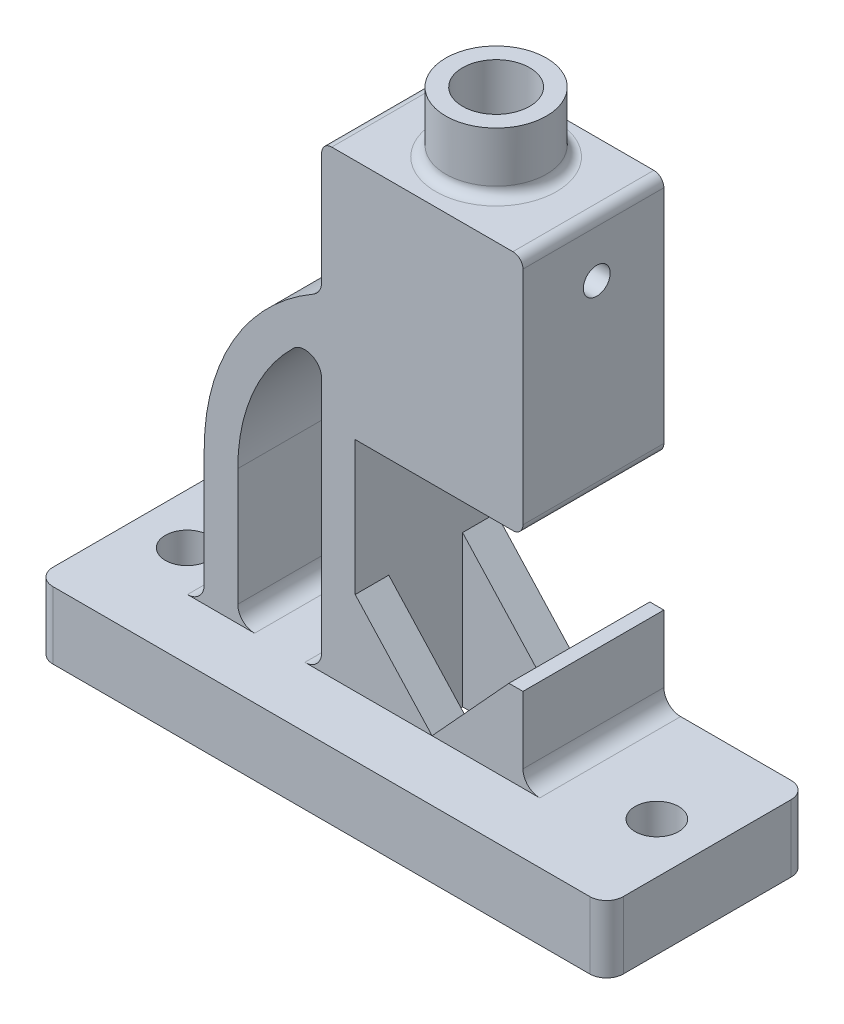
from build123d import *

# Parameters (mm, degrees)
BOSS_EXTRUDE1_DEPTH     = 20
BOSS_EXTRUDE4_START     = -30
BOSS_EXTRUDE4_DEPTH     = 42
SKETCH10_W              = 40
SKETCH10_H              = 22
CUT_EXTRUDE3_DEPTH      = 147
SKETCH11_R              = 15
BOSS_EXTRUDE5_DEPTH     = 18
CUT_EXTRUDE4_REACH      = 177
SKETCH12_R              = 10
FILLET1_R               = 3
SKETCH13_R              = 4
CUT_EXTRUDE5_DEPTH      = 86
CUT_EXTRUDE5_DEPTH_BACK = 86
CUT_EXTRUDE7_REACH      = 177
SKETCH16_R              = 6.5


with BuildPart() as part:
    # Sketch1 → Boss-Extrude1 (new body)
    with BuildSketch(Plane(origin=(0, 0, 0), x_dir=(1, 0, 0), z_dir=(0, 1, 0))):
        with BuildLine():
            Line((-80, 30), (80, 30))
            ThreePointArc((80, 30), (83.535533906, 28.535533906), (85, 25))
            Line((85, 25), (85, -25))
            ThreePointArc((85, -25), (83.535533906, -28.535533906), (80, -30))
            Line((80, -30), (-80, -30))
            ThreePointArc((-80, -30), (-83.535533906, -28.535533906), (-85, -25))
            Line((-85, -25), (-85, 25))
            ThreePointArc((-85, 25), (-83.535533906, 28.535533906), (-80, 30))
        make_face()
    extrude(amount=BOSS_EXTRUDE1_DEPTH)

    # Sketch2 → Boss-Extrude4 (add)
    with BuildSketch(Plane.XY.offset(BOSS_EXTRUDE4_START)):
        with BuildLine():
            Line((-17.90827935, 157), (42.09172065, 157))
            Line((42.09172065, 157), (42.09172065, 85))
            Line((42.09172065, 85), (-7.90827935, 85))
            Line((-7.90827935, 85), (-7.90827935, 45))
            Line((-7.90827935, 45), (15, 20))
            Line((15, 20), (37.90827935, 45))
            Line((37.90827935, 45), (42.09172065, 45))
            Line((42.09172065, 45), (42.09172065, 25))
            ThreePointArc((42.09172065, 25), (43.556186744, 21.464466094), (47.09172065, 20))
            Line((47.09172065, 20), (50, 20))
            Line((50, 20), (50, 17))
            Line((50, 17), (-58, 17))
            Line((-58, 17), (-58, 20))
            Line((-58, 20), (-57.90827935, 20))
            ThreePointArc((-57.90827935, 20), (-54.372745445, 21.464466094), (-52.90827935, 25))
            Line((-52.90827935, 25), (-52.90827935, 60))
            ThreePointArc((-52.90827935, 60), (-44.199930596, 92.5), (-20.40827935, 116.291651246))
            ThreePointArc((-20.40827935, 116.291651246), (-18.578152332, 118.121778265), (-17.90827935, 120.621778265))
            Line((-17.90827935, 120.621778265), (-17.90827935, 157))
        make_face()
        with BuildLine():
            Line((-17.90827935, 95.707142143), (-17.90827935, 25))
            ThreePointArc((-17.90827935, 25), (-19.372745445, 21.464466094), (-22.90827935, 20))
            Line((-22.90827935, 20), (-37.90827935, 20))
            ThreePointArc((-37.90827935, 20), (-41.443813256, 21.464466094), (-42.90827935, 25))
            Line((-42.90827935, 25), (-42.90827935, 60))
            ThreePointArc((-42.90827935, 60), (-38.615773866, 81.301408404), (-26.40827935, 99.277856357))
            ThreePointArc((-26.40827935, 99.277856357), (-20.971787677, 100.316914371), (-17.90827935, 95.707142143))
        make_face(mode=Mode.SUBTRACT)
    extrude(amount=BOSS_EXTRUDE4_DEPTH)

    # Sketch10 → Cut-Extrude3 (cut)
    with BuildSketch(Plane(origin=(0, 0, 0), x_dir=(1, 0, 0), z_dir=(0, 1, 0))):
        with Locations((12.09172065, 9)):
            Rectangle(SKETCH10_W, SKETCH10_H)
    extrude(amount=CUT_EXTRUDE3_DEPTH, mode=Mode.SUBTRACT)

    # Sketch11 → Boss-Extrude5 (add)
    with BuildSketch(Plane(origin=(0, 157, 0), x_dir=(1, 0, 0), z_dir=(0, 1, 0))):
        with Locations((12.09172065, 10)):
            Circle(SKETCH11_R)
    extrude(amount=BOSS_EXTRUDE5_DEPTH)

    # Sketch12 → Cut-Extrude4 (cut, up to next)
    with BuildSketch(Plane(origin=(0, 175, 0), x_dir=(1, 0, 0), z_dir=(0, 1, 0)), mode=Mode.PRIVATE) as cut_extrude4_sk1:
        with Locations((12.09172065, 10)):
            Circle(SKETCH12_R)
    cut_extrude4_tool1 = extrude(cut_extrude4_sk1.sketch, amount=-CUT_EXTRUDE4_REACH, mode=Mode.PRIVATE) & part.part
    add(cut_extrude4_tool1.solids().sort_by_distance((12.091721, 175, -10))[0], mode=Mode.SUBTRACT)

    # Fillet1
    fillet1_edges = [part.edges().sort_by_distance(p)[0] for p in [
        (-2.90827935, 157, -10),
        (42.09172065, 85, -9),
        (42.09172065, 157, -9),
        (-17.90827935, 157, -9),
    ]]
    fillet(fillet1_edges, radius=FILLET1_R)

    # Sketch13 → Cut-Extrude5 (cut, two sides)
    with BuildSketch(Plane(origin=(0, 0, 0), x_dir=(0, 0, -1), z_dir=(1, 0, 0))) as cut_extrude5_sk:
        with Locations((10, 140)):
            Circle(SKETCH13_R)
    extrude(amount=CUT_EXTRUDE5_DEPTH, mode=Mode.SUBTRACT)
    extrude(cut_extrude5_sk.sketch, amount=-CUT_EXTRUDE5_DEPTH_BACK, mode=Mode.SUBTRACT)

    # Sketch16 → Cut-Extrude7 (cut, up to next)
    with BuildSketch(Plane(origin=(0, 0, 0), x_dir=(1, 0, 0), z_dir=(0, 1, 0)), mode=Mode.PRIVATE) as cut_extrude7_sk1:
        with Locations((-70, 0)):
            Circle(SKETCH16_R)
    cut_extrude7_tool1 = extrude(cut_extrude7_sk1.sketch, amount=CUT_EXTRUDE7_REACH, mode=Mode.PRIVATE) & part.part
    add(cut_extrude7_tool1.solids().sort_by_distance((-70, 0, 0))[0], mode=Mode.SUBTRACT)
    # Sketch16 → Cut-Extrude7 (cut, up to next)
    with BuildSketch(Plane(origin=(0, 0, 0), x_dir=(1, 0, 0), z_dir=(0, 1, 0)), mode=Mode.PRIVATE) as cut_extrude7_sk2:
        with Locations((70, 0)):
            Circle(SKETCH16_R)
    cut_extrude7_tool2 = extrude(cut_extrude7_sk2.sketch, amount=CUT_EXTRUDE7_REACH, mode=Mode.PRIVATE) & part.part
    add(cut_extrude7_tool2.solids().sort_by_distance((70, 0, 0))[0], mode=Mode.SUBTRACT)


solid = part.part
